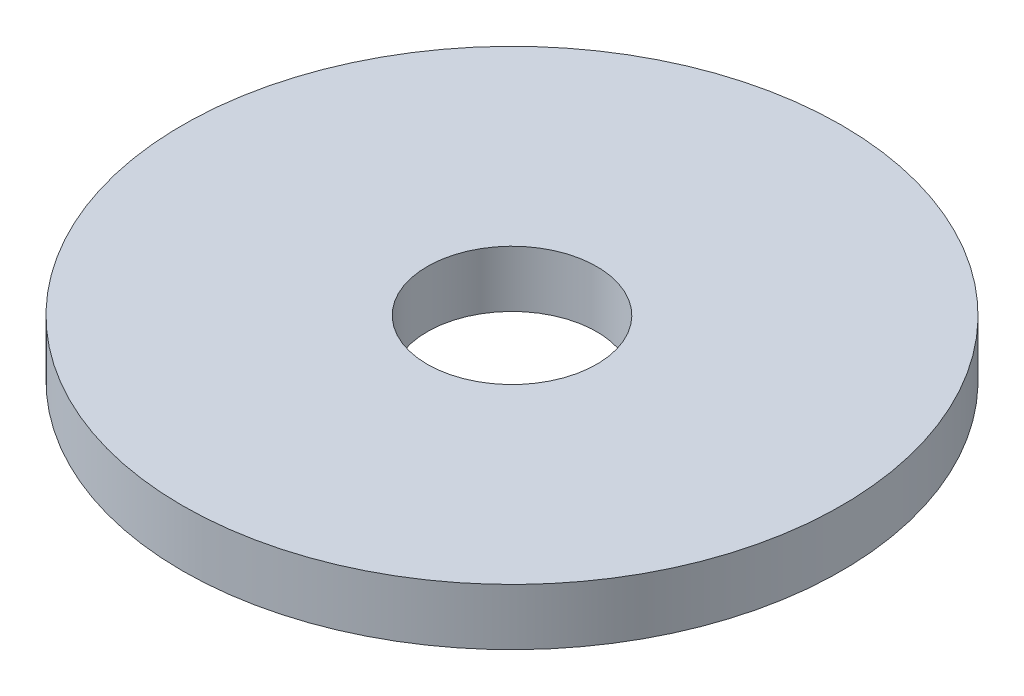
from build123d import *

# Parameters (mm, degrees)
SKETCH1_W = 13
SKETCH1_H = 3


with BuildPart() as part:
    # Sketch1 → Revolve1 (revolve)
    with BuildSketch(Plane.XY):
        with Locations((-11, -1.5)):
            Rectangle(SKETCH1_W, SKETCH1_H)
    revolve(axis=Axis((0, 2.968309859, 0), (0, -1, 0)))


solid = part.part
